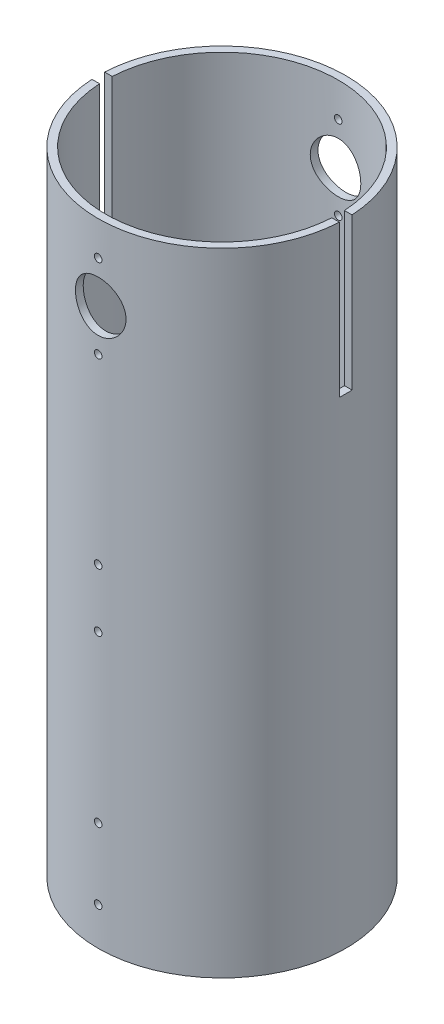
from build123d import *

# Parameters (mm, degrees)
SKETCH7_R               = 49
SKETCH7_R_2             = 46
BOSS_EXTRUDE3_DEPTH     = 250
SKETCH8_R               = 1.5
SKETCH8_R_2             = 10
CUT_EXTRUDE4_DEPTH      = 50
CUT_EXTRUDE4_DEPTH_BACK = 50
SKETCH9_W               = 5
SKETCH9_H               = 60
CUT_EXTRUDE5_DEPTH      = 50.0000001
CUT_EXTRUDE5_DEPTH_BACK = 50.0000001


with BuildPart() as part:
    # Sketch7 → Boss-Extrude3 (new body)
    with BuildSketch(Plane(origin=(0, 0, 0), x_dir=(1, 0, 0), z_dir=(0, 1, 0))):
        Circle(SKETCH7_R)
        Circle(SKETCH7_R_2, mode=Mode.SUBTRACT)
    extrude(amount=BOSS_EXTRUDE3_DEPTH)

    # Sketch8 → Cut-Extrude4 (cut, two sides)
    with BuildSketch(Plane.XY) as cut_extrude4_sk:
        with Locations((0, 15)):
            Circle(SKETCH8_R)
        with Locations((0, 43)):
            Circle(SKETCH8_R)
        with Locations((0, 108.5)):
            Circle(SKETCH8_R)
        with Locations((0, 131.5)):
            Circle(SKETCH8_R)
        with Locations((0, 236.5)):
            Circle(SKETCH8_R)
        with Locations((0, 203.5)):
            Circle(SKETCH8_R)
        with Locations((0, 220)):
            Circle(SKETCH8_R_2)
    extrude(amount=CUT_EXTRUDE4_DEPTH, mode=Mode.SUBTRACT)
    extrude(cut_extrude4_sk.sketch, amount=-CUT_EXTRUDE4_DEPTH_BACK, mode=Mode.SUBTRACT)

    # Sketch9 → Cut-Extrude5 (cut, two sides)
    with BuildSketch(Plane(origin=(0, 0, 0), x_dir=(0, 0, -1), z_dir=(1, 0, 0))) as cut_extrude5_sk:
        with Locations((0, 220)):
            Rectangle(SKETCH9_W, SKETCH9_H)
    extrude(amount=CUT_EXTRUDE5_DEPTH, mode=Mode.SUBTRACT)
    extrude(cut_extrude5_sk.sketch, amount=-CUT_EXTRUDE5_DEPTH_BACK, mode=Mode.SUBTRACT)


solid = part.part
